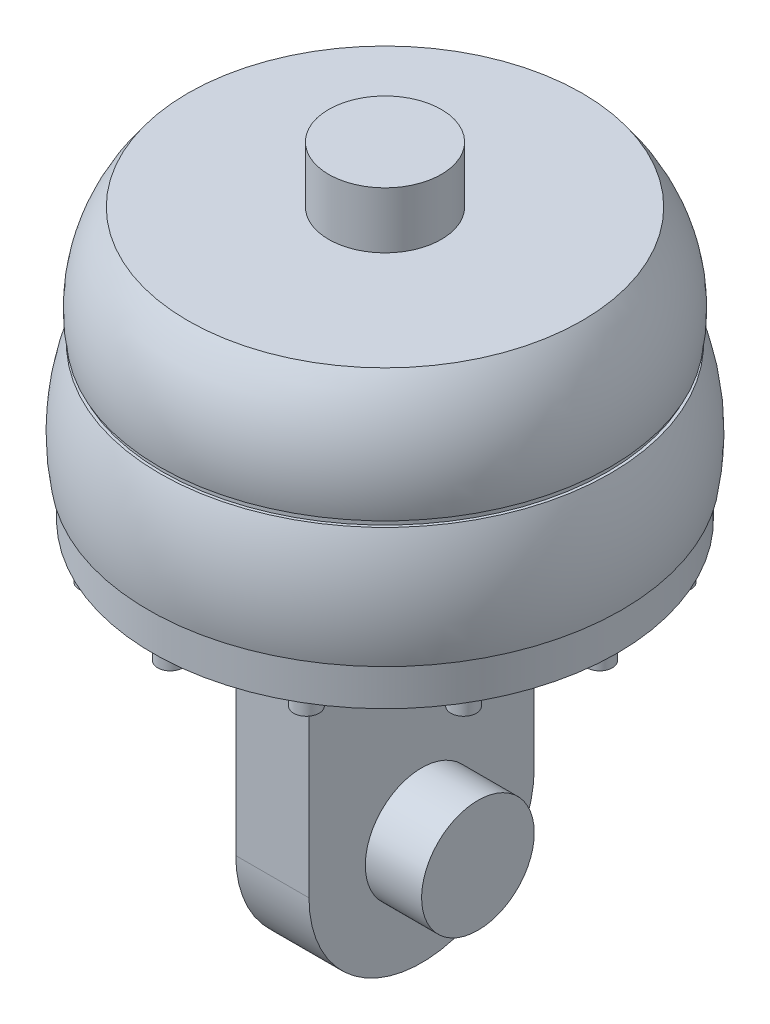
from build123d import *

# Parameters (mm, degrees)
SKETCH2_R           = 39.5
BOSS_EXTRUDE1_DEPTH = 1
SKETCH5_R           = 41.25
BOSS_EXTRUDE2_DEPTH = 7
SKETCH6_R           = 35
BOSS_EXTRUDE3_DEPTH = 3
BOSS_EXTRUDE4_DEPTH = 2.7
SKETCH8_R           = 1.25
CUT_EXTRUDE1_DEPTH  = 0.7
CIRPATTERN1_COUNT   = 12
SKETCH9_W           = 13
SKETCH9_H           = 40
BOSS_EXTRUDE5_DEPTH = 42
BOSS_EXTRUDE7_DEPTH = 13
SKETCH13_R          = 10
BOSS_EXTRUDE8_DEPTH = 10
SKETCH14_R          = 10
BOSS_EXTRUDE9_DEPTH = 10


with BuildPart() as part:
    # Sketch1 → Revolve1 (revolve)
    with BuildSketch(Plane.XY):
        with BuildLine():
            Line((0, 0), (-35, 0))
            ThreePointArc((-35, 0), (-39.657515479, -9.46062113), (-40, -20))
            Line((-40, -20), (0, -20))
            Line((0, -20), (0, 0))
        make_face()
    revolve(axis=Axis((0, 0, 0), (0, -1, 0)))

    # Sketch2 → Boss-Extrude1 (add)
    with BuildSketch(Plane.XZ.offset(20)):
        Circle(SKETCH2_R)
    extrude(amount=BOSS_EXTRUDE1_DEPTH)

    # Sketch4 → Revolve2 (revolve)
    with BuildSketch(Plane.XY):
        with BuildLine():
            Line((0, -21), (0, -41))
            Line((0, -41), (-42, -41))
            ThreePointArc((-42, -41), (-42.384109041, -30.861589096), (-40, -21))
            Line((-40, -21), (0, -21))
        make_face()
    revolve(axis=Axis((0, -21, 0), (0, -1, 0)))

    # Sketch5 → Boss-Extrude2 (add)
    with BuildSketch(Plane.XZ.offset(41)):
        Circle(SKETCH5_R)
    extrude(amount=BOSS_EXTRUDE2_DEPTH)

    # Sketch6 → Boss-Extrude3 (add)
    with BuildSketch(Plane.XZ.offset(48)):
        Circle(SKETCH6_R)
    extrude(amount=BOSS_EXTRUDE3_DEPTH)

    # Sketch7 → Boss-Extrude4 (add)
    with BuildSketch(Plane(origin=(0, -48, 0), x_dir=(-1, 0, 0), z_dir=(0, -1, 0))):
        with BuildLine():
            ThreePointArc((-40.375, 0), (-38.125, -2.25), (-35.875, 0))
            Line((-35.875, 0), (-40.375, 0))
        make_face()
        with BuildLine():
            Line((-40.375, 0), (-35.875, 0))
            ThreePointArc((-35.875, 0), (-38.125, 2.25), (-40.375, 0))
        make_face()
    boss_extrude4 = extrude(amount=BOSS_EXTRUDE4_DEPTH)

    # Sketch8 → Cut-Extrude1 (cut)
    with BuildSketch(Plane.XZ.offset(50.7)):
        with Locations((38.125, 0)):
            Circle(SKETCH8_R)
    cut_extrude1 = extrude(amount=-CUT_EXTRUDE1_DEPTH, mode=Mode.SUBTRACT)

    # CirPattern1: Boss-Extrude4, Cut-Extrude1 ×12 about axis
    cirpattern1_axis = Axis((0, 0, 0), (0, 1, 0))
    for i in range(1, CIRPATTERN1_COUNT):
        add(boss_extrude4.rotate(cirpattern1_axis, i * 360 / CIRPATTERN1_COUNT))
        add(cut_extrude1.rotate(cirpattern1_axis, i * 360 / CIRPATTERN1_COUNT), mode=Mode.SUBTRACT)

    # Sketch9 → Boss-Extrude5 (add)
    with BuildSketch(Plane.XZ.offset(51)):
        Rectangle(SKETCH9_W, SKETCH9_H)
    extrude(amount=BOSS_EXTRUDE5_DEPTH)

    # Sketch12 → Boss-Extrude7 (add)
    with BuildSketch(Plane(origin=(6.5, 0, 0), x_dir=(0, 0, -1), z_dir=(1, 0, 0))):
        with BuildLine():
            Line((20, -93), (-20, -93))
            ThreePointArc((-20, -93), (0, -113), (20, -93))
        make_face()
    extrude(amount=-BOSS_EXTRUDE7_DEPTH)

    # Sketch13 → Boss-Extrude8 (add)
    with BuildSketch(Plane(origin=(6.5, 0, 0), x_dir=(0, 0, -1), z_dir=(1, 0, 0))):
        with Locations((0, -93)):
            Circle(SKETCH13_R)
    extrude(amount=BOSS_EXTRUDE8_DEPTH)

    # Sketch14 → Boss-Extrude9 (add)
    with BuildSketch(Plane(origin=(0, 0, 0), x_dir=(1, 0, 0), z_dir=(0, 1, 0))):
        Circle(SKETCH14_R)
    extrude(amount=BOSS_EXTRUDE9_DEPTH)


solid = part.part
